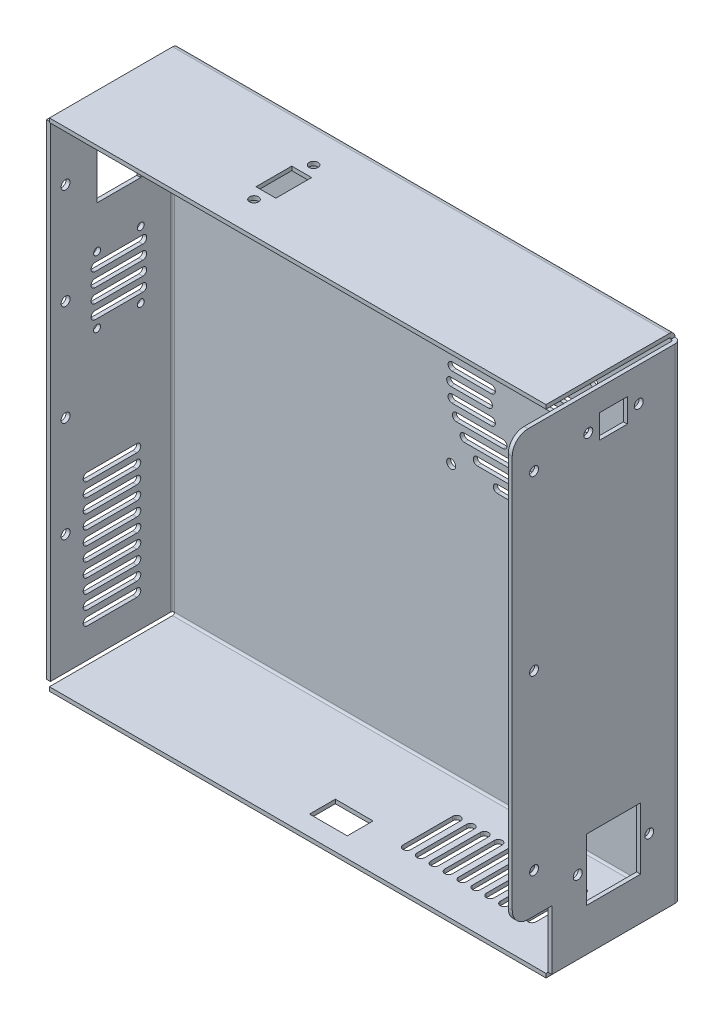
from build123d import *

# Parameters (mm, degrees)
SKETCH1_W           = 256
SKETCH1_H           = 250
BOSS_EXTRUDE1_DEPTH = 2
SKETCH2_W           = 256
SKETCH2_H           = 250
SKETCH2_W_2         = 252
SKETCH2_H_2         = 246
BOSS_EXTRUDE2_DEPTH = 63
FILLET1_R           = 1
FILLET2_R           = 3
SKETCH3_W           = 3
SKETCH3_H           = 3
CUT_EXTRUDE1_DEPTH  = 66
SKETCH4_W           = 2
SKETCH4_H           = 214
BOSS_EXTRUDE3_DEPTH = 20
SKETCH5_R           = 2.25
SKETCH5_R_2         = 1.75
SKETCH5_W           = 22
SKETCH5_H           = 29
CUT_EXTRUDE2_DEPTH  = 15
SKETCH6_R           = 2.25
SKETCH6_W           = 27.3
SKETCH6_H           = 31.1
SKETCH6_W_2         = 14
SKETCH6_H_2         = 12
CUT_EXTRUDE3_DEPTH  = 15
FILLET3_R           = 8
SKETCH7_R           = 2.25
SKETCH7_W           = 10
SKETCH7_H           = 18
CUT_EXTRUDE4_DEPTH  = 15
SKETCH8_R           = 2.25
CUT_EXTRUDE5_DEPTH  = 15
SKETCH9_W           = 19
SKETCH9_H           = 13
CUT_EXTRUDE6_DEPTH  = 15
SKETCH10_W          = 2
SKETCH10_H          = 244
CUT_EXTRUDE7_DEPTH  = 1.5


with BuildPart() as part:
    # Sketch1 → Boss-Extrude1 (new body)
    with BuildSketch(Plane.XY):
        Rectangle(SKETCH1_W, SKETCH1_H)
    extrude(amount=BOSS_EXTRUDE1_DEPTH)

    # Sketch2 → Boss-Extrude2 (add)
    with BuildSketch(Plane.XY.offset(2)):
        Rectangle(SKETCH2_W, SKETCH2_H)
        Rectangle(SKETCH2_W_2, SKETCH2_H_2, mode=Mode.SUBTRACT)
    extrude(amount=BOSS_EXTRUDE2_DEPTH)

    # Fillet1
    fillet1_edges = [part.edges().sort_by_distance(p)[0] for p in [
        (-126, 0, 2),
        (0, -123, 2),
        (126, 0, 2),
        (0, 123, 2),
    ]]
    fillet(fillet1_edges, radius=FILLET1_R)

    # Fillet2
    fillet2_edges = [part.edges().sort_by_distance(p)[0] for p in [
        (0, 125, 0),
        (128, 0, 0),
        (0, -125, 0),
        (-128, 0, 0),
    ]]
    fillet(fillet2_edges, radius=FILLET2_R)

    # Sketch3 → Cut-Extrude1 (cut, through all)
    with BuildSketch(Plane.XY.offset(65)):
        with Locations((-126.5, 123.5)):
            Rectangle(SKETCH3_W, SKETCH3_H)
        with Locations((126.5, 123.5)):
            Rectangle(SKETCH3_W, SKETCH3_H)
        with Locations((126.5, -123.5)):
            Rectangle(SKETCH3_W, SKETCH3_H)
        with Locations((-126.5, -123.5)):
            Rectangle(SKETCH3_W, SKETCH3_H)
    extrude(amount=-CUT_EXTRUDE1_DEPTH, mode=Mode.SUBTRACT)

    # Sketch4 → Boss-Extrude3 (add)
    with BuildSketch(Plane.XY.offset(65)):
        with Locations((127, 15)):
            Rectangle(SKETCH4_W, SKETCH4_H)
    extrude(amount=BOSS_EXTRUDE3_DEPTH)

    # Sketch5 → Cut-Extrude2 (cut)
    with BuildSketch(Plane.ZY.offset(128)):
        with Locations(Location((55.8527, 90.8, 0), (0, 0, 270))):  # turned: the seam where the file's is
            Circle(SKETCH5_R)
        with Locations(Location((55.8527, 40, 0), (0, 0, 270))):  # turned: the seam where the file's is
            Circle(SKETCH5_R)
        with Locations(Location((55.8527, -10.8, 0), (0, 0, 270))):  # turned: the seam where the file's is
            Circle(SKETCH5_R)
        with Locations(Location((55.8527, -61.6, 0), (0, 0, 270))):  # turned: the seam where the file's is
            Circle(SKETCH5_R)
        with Locations(Location((18, 53.75, 0), (0, 0, 270))):  # turned: the seam where the file's is
            Circle(SKETCH5_R_2)
        with Locations(Location((40, 53.75, 0), (0, 0, 270))):  # turned: the seam where the file's is
            Circle(SKETCH5_R_2)
        with Locations(Location((18, 20.25, 0), (0, 0, 270))):  # turned: the seam where the file's is
            Circle(SKETCH5_R_2)
        with Locations(Location((40, 20.25, 0), (0, 0, 270))):  # turned: the seam where the file's is
            Circle(SKETCH5_R_2)
        with Locations((29, 89.5)):
            Rectangle(SKETCH5_W, SKETCH5_H)
        with BuildLine():
            Line((20, -68), (45, -68))
            ThreePointArc((45, -68), (47, -70), (45, -72))
            Line((45, -72), (20, -72))
            ThreePointArc((20, -72), (18, -70), (20, -68))
        make_face()
        with BuildLine():
            Line((20, -75), (45, -75))
            ThreePointArc((45, -75), (47, -77), (45, -79))
            Line((45, -79), (20, -79))
            ThreePointArc((20, -79), (18, -77), (20, -75))
        make_face()
        with BuildLine():
            Line((20, -82), (45, -82))
            ThreePointArc((45, -82), (47, -84), (45, -86))
            Line((45, -86), (20, -86))
            ThreePointArc((20, -86), (18, -84), (20, -82))
        make_face()
        with BuildLine():
            Line((20, -89), (45, -89))
            ThreePointArc((45, -89), (47, -91), (45, -93))
            Line((45, -93), (20, -93))
            ThreePointArc((20, -93), (18, -91), (20, -89))
        make_face()
        with BuildLine():
            Line((20, -96), (45, -96))
            ThreePointArc((45, -96), (47, -98), (45, -100))
            Line((45, -100), (20, -100))
            ThreePointArc((20, -100), (18, -98), (20, -96))
        make_face()
        with BuildLine():
            Line((20, -103), (45, -103))
            ThreePointArc((45, -103), (47, -105), (45, -107))
            Line((45, -107), (20, -107))
            ThreePointArc((20, -107), (18, -105), (20, -103))
        make_face()
        with BuildLine():
            Line((20, -61), (45, -61))
            ThreePointArc((45, -61), (47, -63), (45, -65))
            Line((45, -65), (20, -65))
            ThreePointArc((20, -65), (18, -63), (20, -61))
        make_face()
        with BuildLine():
            Line((20, -54), (45, -54))
            ThreePointArc((45, -54), (47, -56), (45, -58))
            Line((45, -58), (20, -58))
            ThreePointArc((20, -58), (18, -56), (20, -54))
        make_face()
        with BuildLine():
            Line((20, -47), (45, -47))
            ThreePointArc((45, -47), (47, -49), (45, -51))
            Line((45, -51), (20, -51))
            ThreePointArc((20, -51), (18, -49), (20, -47))
        make_face()
        with BuildLine():
            Line((20, -40), (45, -40))
            ThreePointArc((45, -40), (47, -42), (45, -44))
            Line((45, -44), (20, -44))
            ThreePointArc((20, -44), (18, -42), (20, -40))
        make_face()
        with BuildLine():
            Line((17, 49.5), (41, 49.5))
            ThreePointArc((41, 49.5), (43, 47.5), (41, 45.5))
            Line((41, 45.5), (17, 45.5))
            ThreePointArc((17, 45.5), (15, 47.5), (17, 49.5))
        make_face()
        with BuildLine():
            Line((17, 42.5), (41, 42.5))
            ThreePointArc((41, 42.5), (43, 40.5), (41, 38.5))
            Line((41, 38.5), (17, 38.5))
            ThreePointArc((17, 38.5), (15, 40.5), (17, 42.5))
        make_face()
        with BuildLine():
            Line((17, 35.5), (41, 35.5))
            ThreePointArc((41, 35.5), (43, 33.5), (41, 31.5))
            Line((41, 31.5), (17, 31.5))
            ThreePointArc((17, 31.5), (15, 33.5), (17, 35.5))
        make_face()
        with BuildLine():
            Line((17, 28.5), (41, 28.5))
            ThreePointArc((41, 28.5), (43, 26.5), (41, 24.5))
            Line((41, 24.5), (17, 24.5))
            ThreePointArc((17, 24.5), (15, 26.5), (17, 28.5))
        make_face()
    extrude(amount=-CUT_EXTRUDE2_DEPTH, mode=Mode.SUBTRACT)

    # Sketch6 → Cut-Extrude3 (cut)
    with BuildSketch(Plane(origin=(128, 0, 0), x_dir=(0, 0, -1), z_dir=(1, 0, 0))):
        with Locations(Location((-16, -85, 0), (0, 0, 90))):  # turned: the seam where the file's is
            Circle(SKETCH6_R)
        with Locations(Location((-52, -85, 0), (0, 0, 90))):  # turned: the seam where the file's is
            Circle(SKETCH6_R)
        with Locations(Location((-46.7, 105, 0), (0, 0, 90))):  # turned: the seam where the file's is
            Circle(SKETCH6_R)
        with Locations(Location((-21.3, 105, 0), (0, 0, 90))):  # turned: the seam where the file's is
            Circle(SKETCH6_R)
        with Locations(Location((-74, -72, 0), (0, 0, 90))):  # turned: the seam where the file's is
            Circle(SKETCH6_R)
        with Locations(Location((-74, 15, 0), (0, 0, 90))):  # turned: the seam where the file's is
            Circle(SKETCH6_R)
        with Locations(Location((-74, 102, 0), (0, 0, 90))):  # turned: the seam where the file's is
            Circle(SKETCH6_R)
        with Locations((-34, -85)):
            Rectangle(SKETCH6_W, SKETCH6_H)
        with Locations((-34, 105)):
            Rectangle(SKETCH6_W_2, SKETCH6_H_2)
    extrude(amount=-CUT_EXTRUDE3_DEPTH, mode=Mode.SUBTRACT)

    # Fillet3
    fillet3_edges = [part.edges().sort_by_distance(p)[0] for p in [
        (127, -92, 85),
        (127, 122, 85),
    ]]
    fillet(fillet3_edges, radius=FILLET3_R)

    # Sketch7 → Cut-Extrude4 (cut)
    with BuildSketch(Plane(origin=(0, 125, 0), x_dir=(1, 0, 0), z_dir=(0, 1, 0))):
        with Locations(Location((-38, -19, 0), (0, 0, 270))):  # turned: the seam where the file's is
            Circle(SKETCH7_R)
        with Locations(Location((-38, -49, 0), (0, 0, 270))):  # turned: the seam where the file's is
            Circle(SKETCH7_R)
        with Locations((-38, -34)):
            Rectangle(SKETCH7_W, SKETCH7_H)
    extrude(amount=-CUT_EXTRUDE4_DEPTH, mode=Mode.SUBTRACT)

    # Sketch8 → Cut-Extrude5 (cut)
    with BuildSketch(Plane(origin=(0, 0, 0), x_dir=(-1, 0, 0), z_dir=(0, 0, -1))):
        with Locations((-85.75, 83.75)):
            Circle(SKETCH8_R)
        with Locations((-85.75, 12.25)):
            Circle(SKETCH8_R)
        with Locations((-14.25, 83.75)):
            Circle(SKETCH8_R)
        with Locations((-14.25, 12.25)):
            Circle(SKETCH8_R)
        with BuildLine():
            Line((-86, 50), (-67, 50))
            ThreePointArc((-67, 50), (-65, 48), (-67, 46))
            Line((-67, 46), (-86, 46))
            ThreePointArc((-86, 46), (-88, 48), (-86, 50))
        make_face()
        with BuildLine():
            Line((-79.240383034, 71), (-20.759616966, 71))
            ThreePointArc((-20.759616966, 71), (-18.759616966, 69), (-20.759616966, 67))
            Line((-20.759616966, 67), (-79.240383034, 67))
            ThreePointArc((-79.240383034, 67), (-81.240383034, 69), (-79.240383034, 71))
        make_face()
        with BuildLine():
            Line((-83.166247904, 64), (-59.643650761, 64))
            ThreePointArc((-59.643650761, 64), (-57.643650761, 62), (-59.643650761, 60))
            Line((-59.643650761, 60), (-83.166247904, 60))
            ThreePointArc((-83.166247904, 60), (-85.166247904, 62), (-83.166247904, 64))
        make_face()
        with BuildLine():
            Line((-85.312887166, 57), (-65.491933385, 57))
            ThreePointArc((-65.491933385, 57), (-63.491933385, 55), (-65.491933385, 53))
            Line((-65.491933385, 53), (-85.312887166, 53))
            ThreePointArc((-85.312887166, 53), (-87.312887166, 55), (-85.312887166, 57))
        make_face()
        with BuildLine():
            Line((-72.627416998, 78), (-27.372583002, 78))
            ThreePointArc((-27.372583002, 78), (-25.372583002, 76), (-27.372583002, 74))
            Line((-27.372583002, 74), (-72.627416998, 74))
            ThreePointArc((-72.627416998, 74), (-74.627416998, 76), (-72.627416998, 78))
        make_face()
        with BuildLine():
            Line((-62.5, 85), (-37.5, 85))
            ThreePointArc((-37.5, 85), (-35.5, 83), (-37.5, 81))
            Line((-37.5, 81), (-62.5, 81))
            ThreePointArc((-62.5, 81), (-64.5, 83), (-62.5, 85))
        make_face()
        with BuildLine():
            Line((-40.356349239, 64), (-16.833752096, 64))
            ThreePointArc((-16.833752096, 64), (-14.833752096, 62), (-16.833752096, 60))
            Line((-16.833752096, 60), (-40.356349239, 60))
            ThreePointArc((-40.356349239, 60), (-42.356349239, 62), (-40.356349239, 64))
        make_face()
        with BuildLine():
            Line((-34.508066615, 57), (-14.687112834, 57))
            ThreePointArc((-14.687112834, 57), (-12.687112834, 55), (-14.687112834, 53))
            Line((-14.687112834, 53), (-34.508066615, 53))
            ThreePointArc((-34.508066615, 53), (-36.508066615, 55), (-34.508066615, 57))
        make_face()
        with BuildLine():
            Line((-33, 50), (-14, 50))
            ThreePointArc((-14, 50), (-12, 48), (-14, 46))
            Line((-14, 46), (-33, 46))
            ThreePointArc((-33, 46), (-35, 48), (-33, 50))
        make_face()
        with BuildLine():
            Line((-34.508066615, 43), (-14.687112834, 43))
            ThreePointArc((-14.687112834, 43), (-12.687112834, 41), (-14.687112834, 39))
            Line((-14.687112834, 39), (-34.508066615, 39))
            ThreePointArc((-34.508066615, 39), (-36.508066615, 41), (-34.508066615, 43))
        make_face()
        with BuildLine():
            Line((-40.356349239, 36), (-16.833752096, 36))
            ThreePointArc((-16.833752096, 36), (-14.833752096, 34), (-16.833752096, 32))
            Line((-16.833752096, 32), (-40.356349239, 32))
            ThreePointArc((-40.356349239, 32), (-42.356349239, 34), (-40.356349239, 36))
        make_face()
        with BuildLine():
            Line((-85.312887166, 43), (-65.491933385, 43))
            ThreePointArc((-65.491933385, 43), (-63.491933385, 41), (-65.491933385, 39))
            Line((-65.491933385, 39), (-85.312887166, 39))
            ThreePointArc((-85.312887166, 39), (-87.312887166, 41), (-85.312887166, 43))
        make_face()
        with BuildLine():
            Line((-83.166247904, 36), (-59.643650761, 36))
            ThreePointArc((-59.643650761, 36), (-57.643650761, 34), (-59.643650761, 32))
            Line((-59.643650761, 32), (-83.166247904, 32))
            ThreePointArc((-83.166247904, 32), (-85.166247904, 34), (-83.166247904, 36))
        make_face()
        with BuildLine():
            Line((-79.240383034, 29), (-20.759616966, 29))
            ThreePointArc((-20.759616966, 29), (-18.759616966, 27), (-20.759616966, 25))
            Line((-20.759616966, 25), (-79.240383034, 25))
            ThreePointArc((-79.240383034, 25), (-81.240383034, 27), (-79.240383034, 29))
        make_face()
        with BuildLine():
            Line((-72.627416998, 22), (-27.372583002, 22))
            ThreePointArc((-27.372583002, 22), (-25.372583002, 20), (-27.372583002, 18))
            Line((-27.372583002, 18), (-72.627416998, 18))
            ThreePointArc((-72.627416998, 18), (-74.627416998, 20), (-72.627416998, 22))
        make_face()
        with BuildLine():
            Line((-62.5, 15), (-37.5, 15))
            ThreePointArc((-37.5, 15), (-35.5, 13), (-37.5, 11))
            Line((-37.5, 11), (-62.5, 11))
            ThreePointArc((-62.5, 11), (-64.5, 13), (-62.5, 15))
        make_face()
    extrude(amount=-CUT_EXTRUDE5_DEPTH, mode=Mode.SUBTRACT)

    # Sketch9 → Cut-Extrude6 (cut)
    with BuildSketch(Plane.XZ.offset(125)):
        with BuildLine():
            Line((44, 45), (44, 20))
            ThreePointArc((44, 20), (42, 18), (40, 20))
            Line((40, 20), (40, 45))
            ThreePointArc((40, 45), (42, 47), (44, 45))
        make_face()
        with BuildLine():
            Line((51, 45), (51, 20))
            ThreePointArc((51, 20), (49, 18), (47, 20))
            Line((47, 20), (47, 45))
            ThreePointArc((47, 45), (49, 47), (51, 45))
        make_face()
        with BuildLine():
            Line((58, 45), (58, 20))
            ThreePointArc((58, 20), (56, 18), (54, 20))
            Line((54, 20), (54, 45))
            ThreePointArc((54, 45), (56, 47), (58, 45))
        make_face()
        with BuildLine():
            Line((65, 45), (65, 20))
            ThreePointArc((65, 20), (63, 18), (61, 20))
            Line((61, 20), (61, 45))
            ThreePointArc((61, 45), (63, 47), (65, 45))
        make_face()
        with BuildLine():
            Line((72, 45), (72, 20))
            ThreePointArc((72, 20), (70, 18), (68, 20))
            Line((68, 20), (68, 45))
            ThreePointArc((68, 45), (70, 47), (72, 45))
        make_face()
        with BuildLine():
            Line((79, 45), (79, 20))
            ThreePointArc((79, 20), (77, 18), (75, 20))
            Line((75, 20), (75, 45))
            ThreePointArc((75, 45), (77, 47), (79, 45))
        make_face()
        with BuildLine():
            Line((86, 45), (86, 20))
            ThreePointArc((86, 20), (84, 18), (82, 20))
            Line((82, 20), (82, 45))
            ThreePointArc((82, 45), (84, 47), (86, 45))
        make_face()
        with BuildLine():
            Line((93, 45), (93, 20))
            ThreePointArc((93, 20), (91, 18), (89, 20))
            Line((89, 20), (89, 45))
            ThreePointArc((89, 45), (91, 47), (93, 45))
        make_face()
        with BuildLine():
            Line((100, 45), (100, 20))
            ThreePointArc((100, 20), (98, 18), (96, 20))
            Line((96, 20), (96, 45))
            ThreePointArc((96, 45), (98, 47), (100, 45))
        make_face()
        with BuildLine():
            Line((37, 45), (37, 20))
            ThreePointArc((37, 20), (35, 18), (33, 20))
            Line((33, 20), (33, 45))
            ThreePointArc((33, 45), (35, 47), (37, 45))
        make_face()
        with Locations((5.5, 48.55)):
            Rectangle(SKETCH9_W, SKETCH9_H)
    extrude(amount=-CUT_EXTRUDE6_DEPTH, mode=Mode.SUBTRACT)

    # Sketch10 → Cut-Extrude7 (cut)
    with BuildSketch(Plane.XY.offset(65)):
        with Locations((-127, 0)):
            Rectangle(SKETCH10_W, SKETCH10_H)
    extrude(amount=-CUT_EXTRUDE7_DEPTH, mode=Mode.SUBTRACT)


solid = part.part
